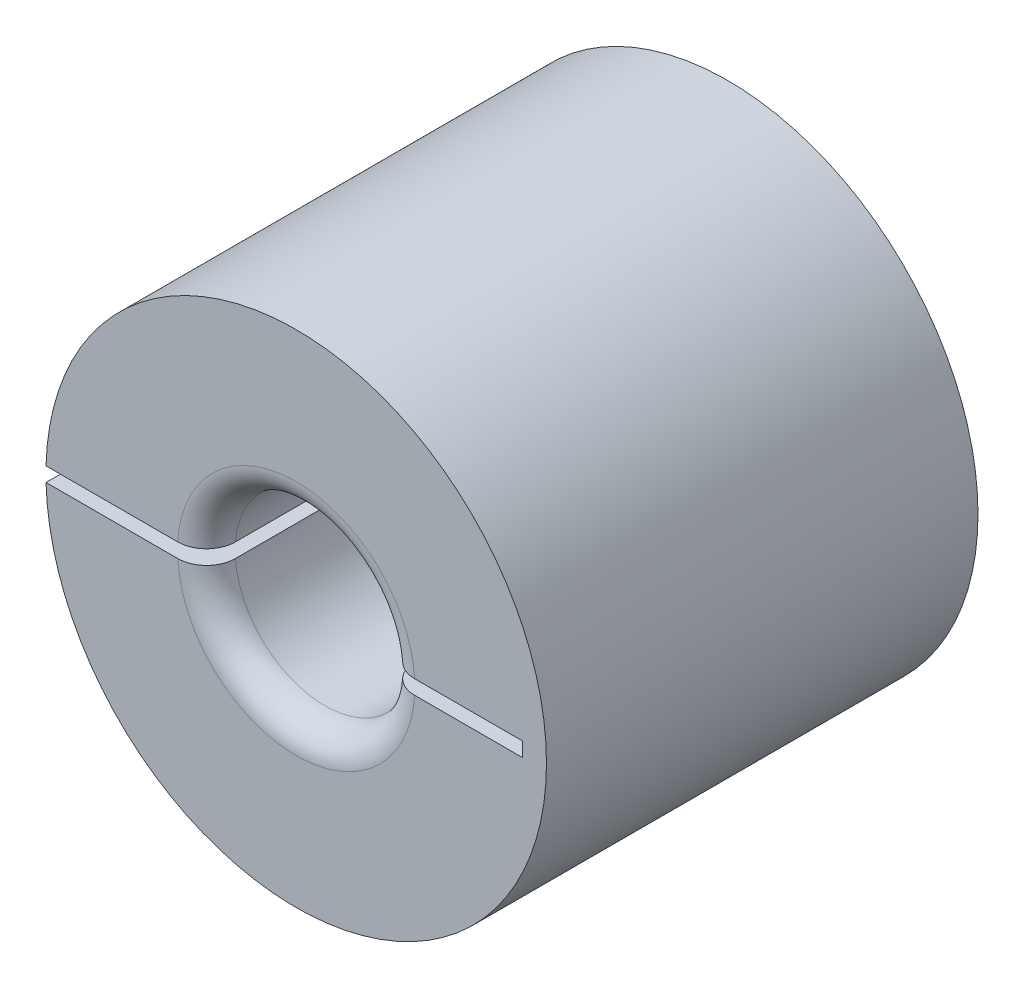
from build123d import *

# Parameters (mm, degrees)
SKETCH1_R           = 11.049
SKETCH1_R_2         = 3.96875
BOSS_EXTRUDE1_DEPTH = 19.05
FILLET1_R           = 1.27
SKETCH3_W           = 21.529859436
SKETCH3_H           = 0.635
CUT_EXTRUDE1_DEPTH  = 20.05


with BuildPart() as part:
    # Sketch1 → Boss-Extrude1 (new body)
    with BuildSketch(Plane.XY):
        Circle(SKETCH1_R)
        Circle(SKETCH1_R_2, mode=Mode.SUBTRACT)
    extrude(amount=BOSS_EXTRUDE1_DEPTH)

    # Fillet1
    fillet1_edges = [part.edges().sort_by_distance(p)[0] for p in [
        (-3.96875, 0, 0),
        (-3.96875, 0, 19.05),
    ]]
    fillet(fillet1_edges, radius=FILLET1_R)

    # Sketch3 → Cut-Extrude1 (cut, through all)
    with BuildSketch(Plane.XY.offset(19.05)):
        with Locations((-0.784069021, 0)):
            Rectangle(SKETCH3_W, SKETCH3_H)
    extrude(amount=-CUT_EXTRUDE1_DEPTH, mode=Mode.SUBTRACT)


solid = part.part
